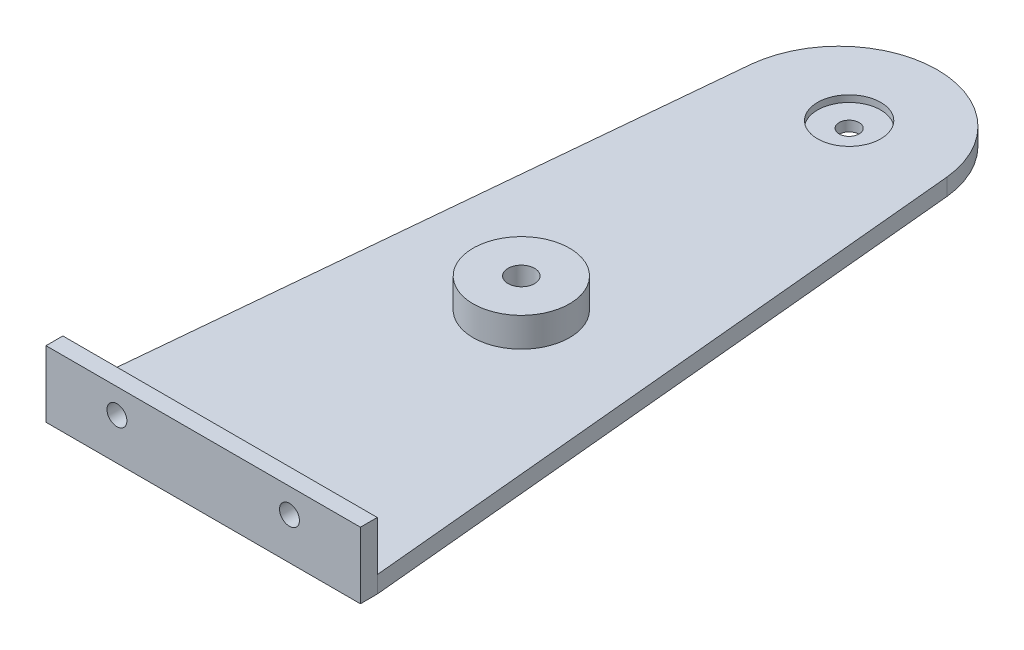
from build123d import *

# Parameters (mm, degrees)
SKETCH2_R           = 1.999999943
BOSS_EXTRUDE3_DEPTH = 2.54
SKETCH3_W           = 47.380920583
SKETCH3_H           = 10
SKETCH3_R           = 1.5
BOSS_EXTRUDE6_DEPTH = 2.54
SKETCH2_5_R         = 1.5
CUT_EXTRUDE1_DEPTH  = 10
SKETCH2_6_R         = 4.7625
SKETCH2_6_R_2       = 1.5
CUT_EXTRUDE2_DEPTH  = 1
SKETCH2_7_R         = 7.267969402
SKETCH2_7_R_2       = 1.999999943
BOSS_EXTRUDE7_DEPTH = 4.420108


with BuildPart() as part:
    # Sketch2 → Boss-Extrude3 (new body)
    with BuildSketch(Plane.XZ):
        with BuildLine():
            Line((14.71851466, 0), (23.68035712, 94.809011723))
            Line((23.68035712, 94.809011723), (-23.700563463, 94.809011723))
            Line((-23.700563463, 94.809011723), (-14.758927346, 0))
            ThreePointArc((-14.758927346, 0), (-0.020206343, -13.282171548), (14.71851466, 0))
        make_face()
        with Locations((-0.020206343, 49.398276345)):
            Circle(SKETCH2_R, mode=Mode.SUBTRACT)
    extrude(amount=BOSS_EXTRUDE3_DEPTH)

    # Sketch3 → Boss-Extrude6 (add)
    with BuildSketch(Plane.XY.offset(94.809011723)):
        with Locations((-0.010103172, 2.46)):
            Rectangle(SKETCH3_W, SKETCH3_H)
        with Locations((-13.010103172, 3.73)):
            Circle(SKETCH3_R, mode=Mode.SUBTRACT)
        with Locations((12.989896828, 3.73)):
            Circle(SKETCH3_R, mode=Mode.SUBTRACT)
    extrude(amount=BOSS_EXTRUDE6_DEPTH)

    # Sketch2_5 → Cut-Extrude1 (cut)
    with BuildSketch(Plane.XZ):
        with Locations((-0.020206343, 0)):
            Circle(SKETCH2_5_R)
    extrude(amount=CUT_EXTRUDE1_DEPTH, mode=Mode.SUBTRACT)

    # Sketch2_6 → Cut-Extrude2 (cut)
    with BuildSketch(Plane.XZ):
        with Locations((-0.020206343, 0)):
            Circle(SKETCH2_6_R)
        with Locations((-0.020206343, 0)):
            Circle(SKETCH2_6_R_2, mode=Mode.SUBTRACT)
    extrude(amount=CUT_EXTRUDE2_DEPTH, mode=Mode.SUBTRACT)

    # Sketch2_7 → Boss-Extrude7 (add)
    with BuildSketch(Plane.XZ):
        with Locations((-0.020206343, 49.398276345)):
            Circle(SKETCH2_7_R)
        with Locations((-0.020206343, 49.398276345)):
            Circle(SKETCH2_7_R_2, mode=Mode.SUBTRACT)
    extrude(amount=-BOSS_EXTRUDE7_DEPTH)


solid = part.part
